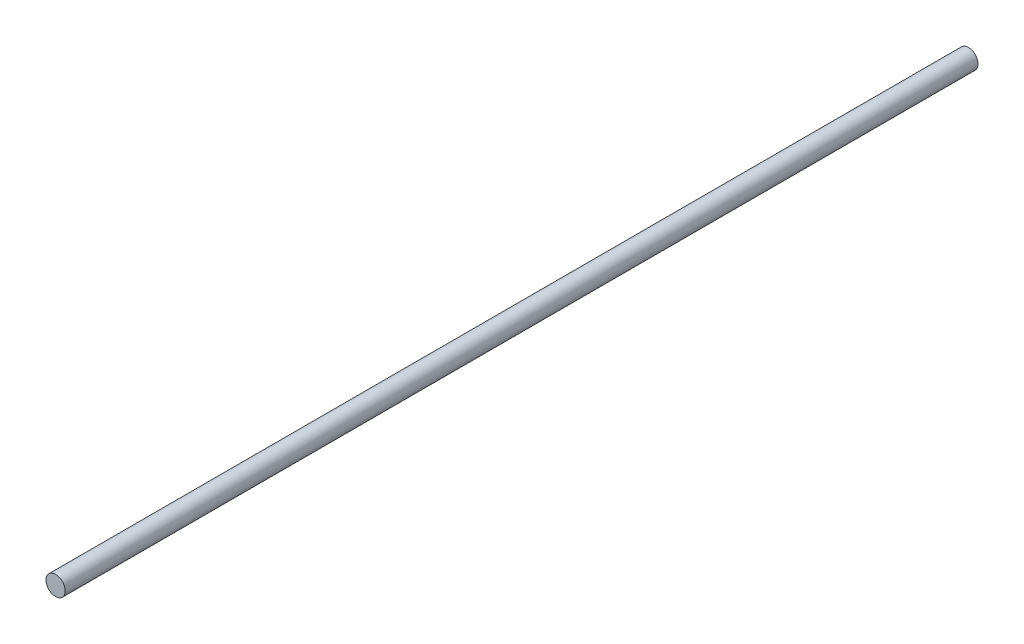
from build123d import *

# Parameters (mm, degrees)
SKETCH1_R           = 3
BOSS_EXTRUDE1_DEPTH = 285


with BuildPart() as part:
    # Sketch1 → Boss-Extrude1 (new body)
    with BuildSketch(Plane.XY):
        Circle(SKETCH1_R)
    extrude(amount=BOSS_EXTRUDE1_DEPTH)


solid = part.part
